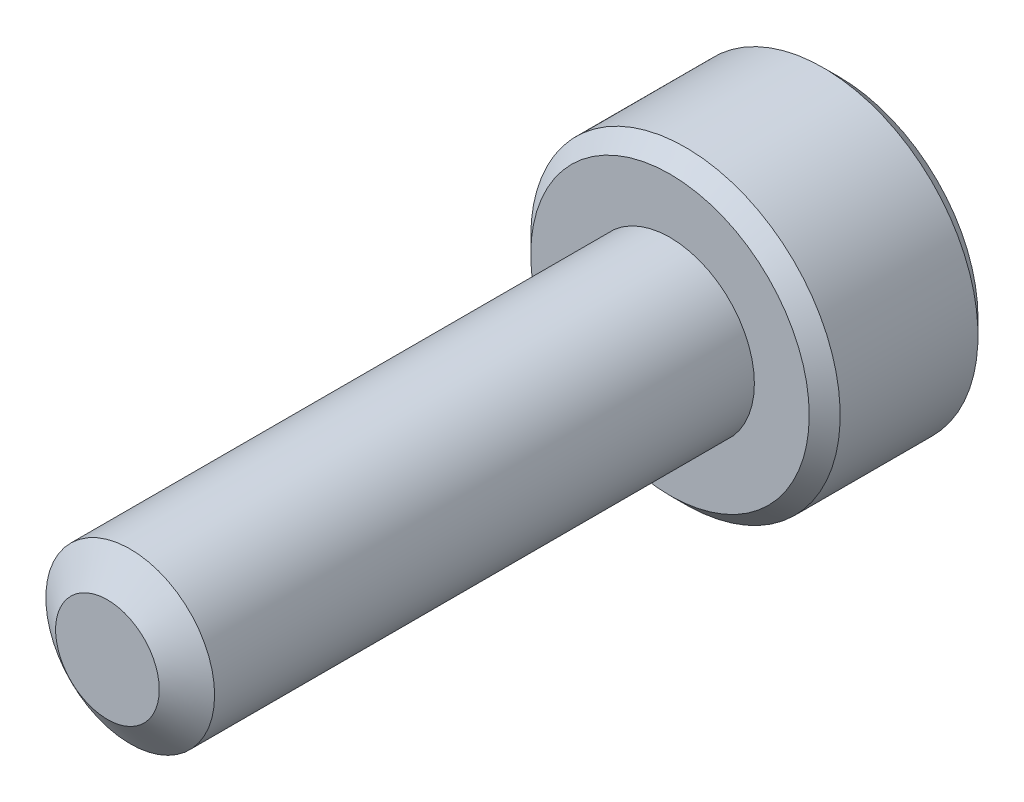
from build123d import *

# Parameters (mm, degrees)
SKETCH1_R          = 1.5
EXTRUDE1_DEPTH     = 10
SKETCH6_R          = 2.75
EXTRUDE2_DEPTH     = 3
CUT_EXTRUDE1_DEPTH = 1.875
CHAMFER1_SIZE      = 0.275


with BuildPart() as part:
    # Sketch1 → Extrude1 (new body)
    with BuildSketch(Plane.XY):
        Circle(SKETCH1_R)
    extrude(amount=-EXTRUDE1_DEPTH)

    # Sketch4 → Cut-Revolve1 (revolve, cut)
    with BuildSketch(Plane(origin=(0, 0, 0), x_dir=(0, 0, -1), z_dir=(1, 0, 0))):
        Polygon((0.405251783, 1.5), (0, 0.921240474), (0, 1.5), align=None)
    revolve(axis=Axis((0, 0, 0), (0, 0, -1)), mode=Mode.SUBTRACT)

    # Sketch6 → Extrude2 (add)
    with BuildSketch(Plane(origin=(0, 0, -10), x_dir=(-1, 0, 0), z_dir=(0, 0, -1))):
        Circle(SKETCH6_R)
    extrude(amount=EXTRUDE2_DEPTH)

    # Sketch7 → Cut-Extrude1 (cut)
    with BuildSketch(Plane(origin=(0, 0, -13), x_dir=(-1, 0, 0), z_dir=(0, 0, -1))):
        Polygon((0, 1.443375673), (-1.25, 0.721687836), (-1.25, -0.721687836), (0, -1.443375673), (1.25, -0.721687836), (1.25, 0.721687836), align=None)
    extrude(amount=-CUT_EXTRUDE1_DEPTH, mode=Mode.SUBTRACT)

    # Cut-Extrude2 cone 1 section (through the dimple's axis) → Cut-Extrude2 (revolve, cut)
    with BuildSketch(Plane(origin=(0, 0, -13), x_dir=(0, 1, 0), z_dir=(1, 0, 0))):
        Polygon((0, 0), (1.443375673, 0), (0, 1.443375673), align=None)
    revolve(axis=Axis((0, 0, -13), (0, 0, 1)), mode=Mode.SUBTRACT)

    # Chamfer1
    chamfer1_edges = [part.edges().sort_by_distance(p)[0] for p in [
        (2.75, 0, -13),
        (2.75, 0, -10),
    ]]
    chamfer(chamfer1_edges, length=CHAMFER1_SIZE)


solid = part.part
